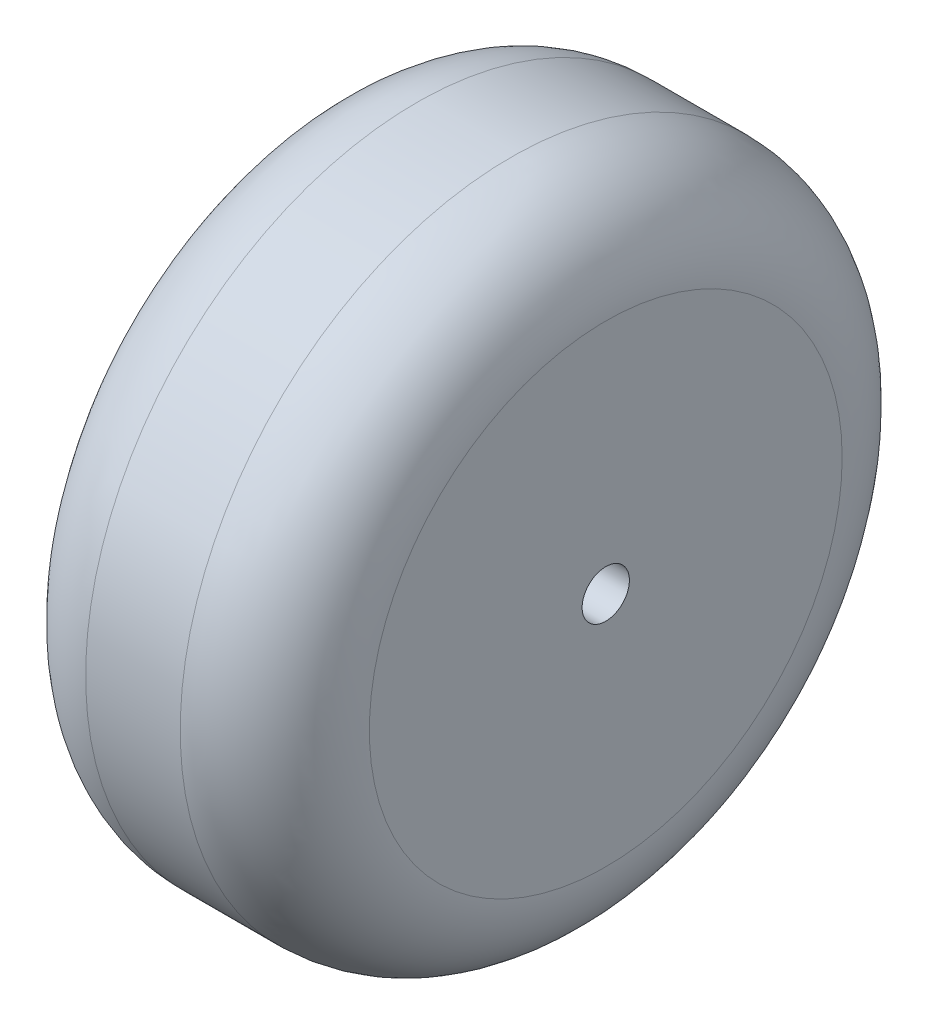
from build123d import *

# Parameters (mm, degrees)
SKETCH_1_R        = 35
SKETCH_1_R_2      = 2.5
EXTRUDE_313_DEPTH = 30
FILLET_2_R        = 10


with BuildPart() as part:
    # Эскиз1 → Extrude 313 (new body)
    with BuildSketch(Plane(origin=(0, 0, 0), x_dir=(0, 0, -1), z_dir=(1, 0, 0))):
        Circle(SKETCH_1_R)
        Circle(SKETCH_1_R_2, mode=Mode.SUBTRACT)
    extrude(amount=EXTRUDE_313_DEPTH)

    # Скругление2
    fillet_2_edges = [part.edges().sort_by_distance(p)[0] for p in [
        (0, 0, 35),
        (30, 0, 35),
    ]]
    fillet(fillet_2_edges, radius=FILLET_2_R)


solid = part.part
